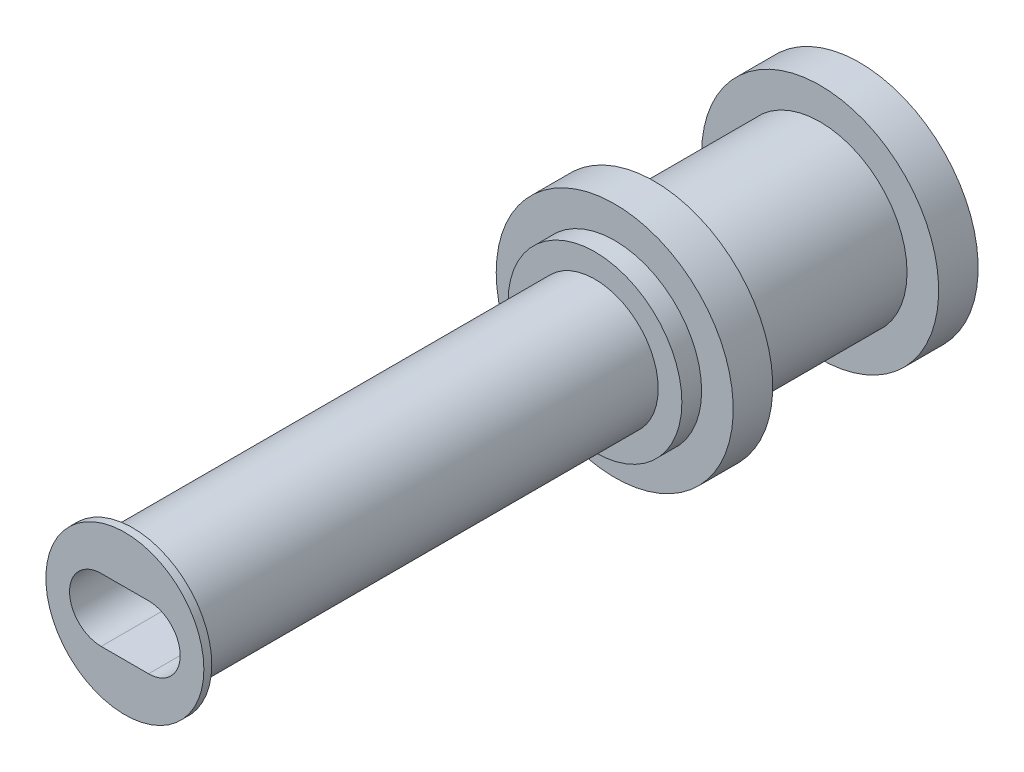
from build123d import *

# Parameters (mm, degrees)
SKETCH1_R           = 2.794
BOSS_EXTRUDE1_DEPTH = 3.937
SKETCH2_R           = 3.81
SKETCH2_R_2         = 2.794
BOSS_EXTRUDE2_DEPTH = 1.27
SKETCH3_R           = 2.794
BOSS_EXTRUDE3_DEPTH = 0.635
SKETCH4_R           = 2.032
BOSS_EXTRUDE4_DEPTH = 15.113
SKETCH5_R           = 2.54
SKETCH5_R_2         = 2.032
BOSS_EXTRUDE5_DEPTH = 0.254
CUT_EXTRUDE1_DEPTH  = 15.24


with BuildPart() as part:
    # Sketch1 → Boss-Extrude1 (new body)
    with BuildSketch(Plane.XY):
        with Locations((7.874, 0)):
            Circle(SKETCH1_R)
        with BuildLine():
            Line((6.35, 0.762), (7.112, 0.762))
            Line((7.112, 0.762), (7.112, 1.524))
            ThreePointArc((7.112, 1.524), (7.874, 2.286), (8.636, 1.524))
            Line((8.636, 1.524), (8.636, 0.762))
            Line((8.636, 0.762), (9.398, 0.762))
            ThreePointArc((9.398, 0.762), (10.16, 0), (9.398, -0.762))
            Line((9.398, -0.762), (8.636, -0.762))
            Line((8.636, -0.762), (8.636, -1.524))
            ThreePointArc((8.636, -1.524), (7.874, -2.286), (7.112, -1.524))
            Line((7.112, -1.524), (7.112, -0.762))
            Line((7.112, -0.762), (6.35, -0.762))
            ThreePointArc((6.35, -0.762), (5.588, 0), (6.35, 0.762))
        make_face(mode=Mode.SUBTRACT)
    boss_extrude1 = extrude(amount=BOSS_EXTRUDE1_DEPTH)

    # Sketch2 → Boss-Extrude2 (add)
    with BuildSketch(Plane(origin=(0, 0, 0), x_dir=(-1, 0, 0), z_dir=(0, 0, -1))):
        with Locations((-7.874, 0)):
            Circle(SKETCH2_R)
        with Locations((-7.874, 0)):
            Circle(SKETCH2_R_2, mode=Mode.SUBTRACT)
    boss_extrude2 = extrude(amount=-BOSS_EXTRUDE2_DEPTH)

    # Mirror1: Boss-Extrude1, Boss-Extrude2 across plane
    add(boss_extrude1.mirror(Plane.XY.offset(3.937)))
    add(boss_extrude2.mirror(Plane.XY.offset(3.937)))

    # Sketch3 → Boss-Extrude3 (add)
    with BuildSketch(Plane.XY.offset(7.874)):
        with Locations((7.874, 0)):
            Circle(SKETCH3_R)
    extrude(amount=BOSS_EXTRUDE3_DEPTH)

    # Sketch4 → Boss-Extrude4 (add)
    with BuildSketch(Plane.XY.offset(8.509)):
        with Locations((7.874, 0)):
            Circle(SKETCH4_R)
    extrude(amount=BOSS_EXTRUDE4_DEPTH)

    # Sketch5 → Boss-Extrude5 (add)
    with BuildSketch(Plane.XY.offset(23.622)):
        with Locations((7.874, 0)):
            Circle(SKETCH5_R)
        with Locations((7.874, 0)):
            Circle(SKETCH5_R_2, mode=Mode.SUBTRACT)
    extrude(amount=-BOSS_EXTRUDE5_DEPTH)

    # Sketch6 → Cut-Extrude1 (cut)
    with BuildSketch(Plane.XY.offset(23.622)):
        with BuildLine():
            Line((8.636, -1.016), (7.112, -1.016))
            ThreePointArc((7.112, -1.016), (6.096, 0), (7.112, 1.016))
            Line((7.112, 1.016), (8.636, 1.016))
            ThreePointArc((8.636, 1.016), (9.652, 0), (8.636, -1.016))
        make_face()
    extrude(amount=-CUT_EXTRUDE1_DEPTH, mode=Mode.SUBTRACT)


solid = part.part
